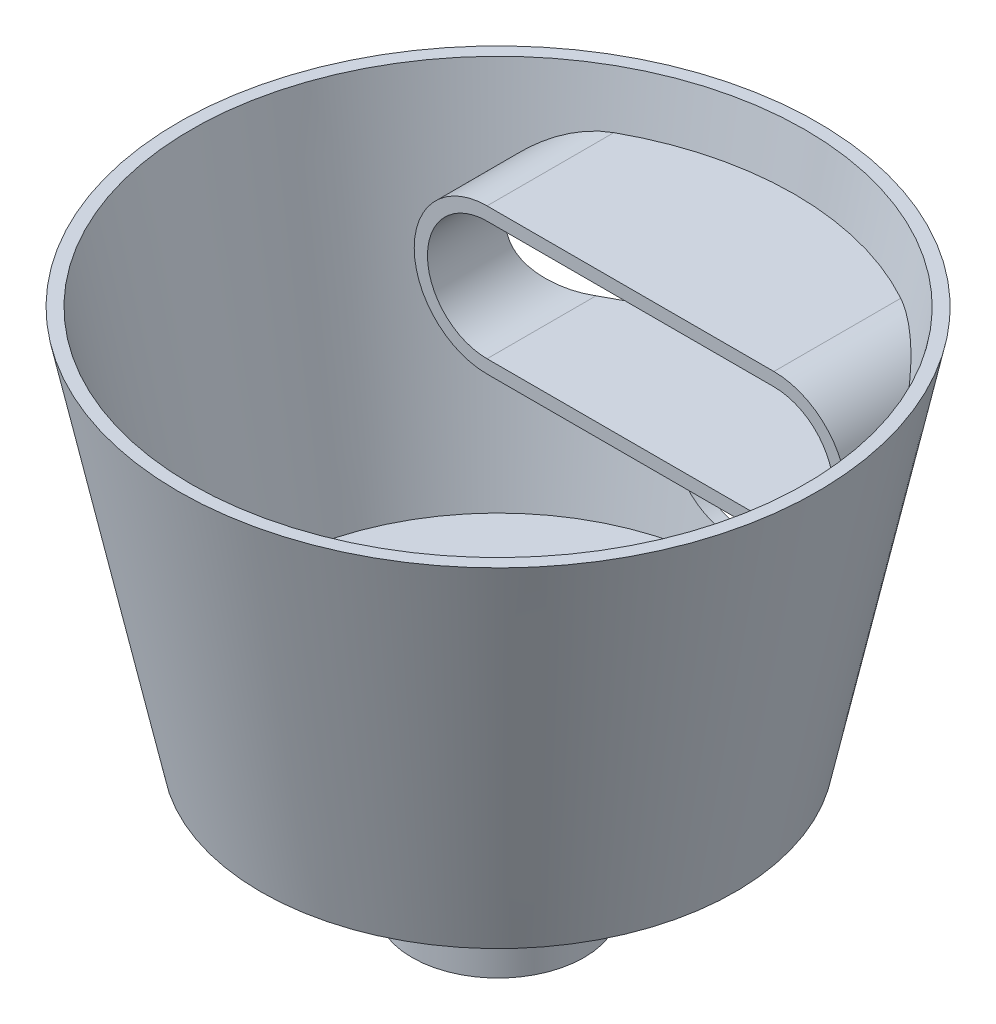
from build123d import *

# Parameters (mm, degrees)
SKETCH1_R               = 75
BOSS_EXTRUDE1_DEPTH     = 100
BOSS_EXTRUDE1_TAPER     = 12
SKETCH3_R               = 70
CUT_EXTRUDE1_DEPTH      = 80
CUT_EXTRUDE1_TAPER      = 12
FILLET1_R               = 10
CUT_EXTRUDE2_DEPTH      = 90
SKETCH5_R               = 19.5
SKETCH5_R_2             = 17.5
BOSS_EXTRUDE2_DEPTH     = 30
SKETCH6_R               = 17.5
CUT_EXTRUDE3_DEPTH      = 30
BOSS_EXTRUDE7_REACH     = 44.651
SKETCH17_R              = 73.5
CUT_EXTRUDE4_DEPTH      = 25
SKETCH18_R              = 3
CUT_EXTRUDE5_DEPTH      = 73.432504542
CUT_EXTRUDE5_DEPTH_BACK = 73.432504542


with BuildPart() as part:
    # Sketch1 → Boss-Extrude1 (new body)
    with BuildSketch(Plane(origin=(0, 0, 0), x_dir=(1, 0, 0), z_dir=(0, 1, 0))):
        Circle(SKETCH1_R)
    extrude(amount=-BOSS_EXTRUDE1_DEPTH, taper=BOSS_EXTRUDE1_TAPER)

    # Sketch3 → Cut-Extrude1 (cut)
    with BuildSketch(Plane(origin=(0, -10, 0), x_dir=(1, 0, 0), z_dir=(0, 1, 0))):
        Circle(SKETCH3_R)
    extrude(amount=-CUT_EXTRUDE1_DEPTH, taper=CUT_EXTRUDE1_TAPER, mode=Mode.SUBTRACT)

    # Fillet1
    fillet1_edges = [part.edges().sort_by_distance(p)[0] for p in [
        (-75, 0, 0),
    ]]
    fillet(fillet1_edges, radius=FILLET1_R)

    # Sketch4 → Cut-Extrude2 (cut)
    with BuildSketch(Plane.XY):
        with BuildLine():
            Line((-15, -70), (15, -70))
            ThreePointArc((15, -70), (0, -85), (-15, -70))
        make_face()
        with BuildLine():
            Line((-32.5, -26.5), (32.5, -26.5))
            ThreePointArc((32.5, -26.5), (46, -40), (32.5, -53.5))
            Line((32.5, -53.5), (-32.5, -53.5))
            ThreePointArc((-32.5, -53.5), (-46, -40), (-32.5, -26.5))
        make_face()
    extrude(amount=-CUT_EXTRUDE2_DEPTH, mode=Mode.SUBTRACT)

    # Sketch5 → Boss-Extrude2 (add)
    with BuildSketch(Plane.XZ.offset(100)):
        Circle(SKETCH5_R)
        Circle(SKETCH5_R_2, mode=Mode.SUBTRACT)
    extrude(amount=BOSS_EXTRUDE2_DEPTH)

    # Sketch6 → Cut-Extrude3 (cut)
    with BuildSketch(Plane.XZ.offset(100)):
        Circle(SKETCH6_R)
    extrude(amount=-CUT_EXTRUDE3_DEPTH, mode=Mode.SUBTRACT)

    # Sketch16 → Boss-Extrude7 (add, up to next)
    with BuildSketch(Plane.XY.offset(-30), mode=Mode.PRIVATE) as boss_extrude7_sk1:
        with BuildLine():
            Line((32.5, -56.5), (-32.5, -56.5))
            ThreePointArc((-32.5, -56.5), (-49, -40), (-32.5, -23.5))
            Line((-32.5, -23.5), (32.5, -23.5))
            ThreePointArc((32.5, -23.5), (49, -40), (32.5, -56.5))
        make_face()
        with BuildLine():
            Line((32.5, -53.5), (-32.5, -53.5))
            ThreePointArc((-32.5, -53.5), (-46, -40), (-32.5, -26.5))
            Line((-32.5, -26.5), (32.5, -26.5))
            ThreePointArc((32.5, -26.5), (46, -40), (32.5, -53.5))
        make_face(mode=Mode.SUBTRACT)
    boss_extrude7_tool1 = extrude(boss_extrude7_sk1.sketch, amount=-BOSS_EXTRUDE7_REACH, mode=Mode.PRIVATE) - part.part
    add(boss_extrude7_tool1.solids().sort_by_distance((0, -55.46593, -30))[0])

    # Sketch17 → Cut-Extrude4 (cut)
    with BuildSketch(Plane(origin=(0, -12.079116908, 0), x_dir=(1, 0, 0), z_dir=(0, 1, 0))):
        Circle(SKETCH17_R)
    extrude(amount=CUT_EXTRUDE4_DEPTH, mode=Mode.SUBTRACT)

    # Sketch18 → Cut-Extrude5 (cut, two sides)
    with BuildSketch(Plane(origin=(0, 0, 0), x_dir=(0, 0, -1), z_dir=(1, 0, 0))) as cut_extrude5_sk:
        with Locations((0, -115)):
            Circle(SKETCH18_R)
    extrude(amount=CUT_EXTRUDE5_DEPTH, mode=Mode.SUBTRACT)
    extrude(cut_extrude5_sk.sketch, amount=-CUT_EXTRUDE5_DEPTH_BACK, mode=Mode.SUBTRACT)


solid = part.part
